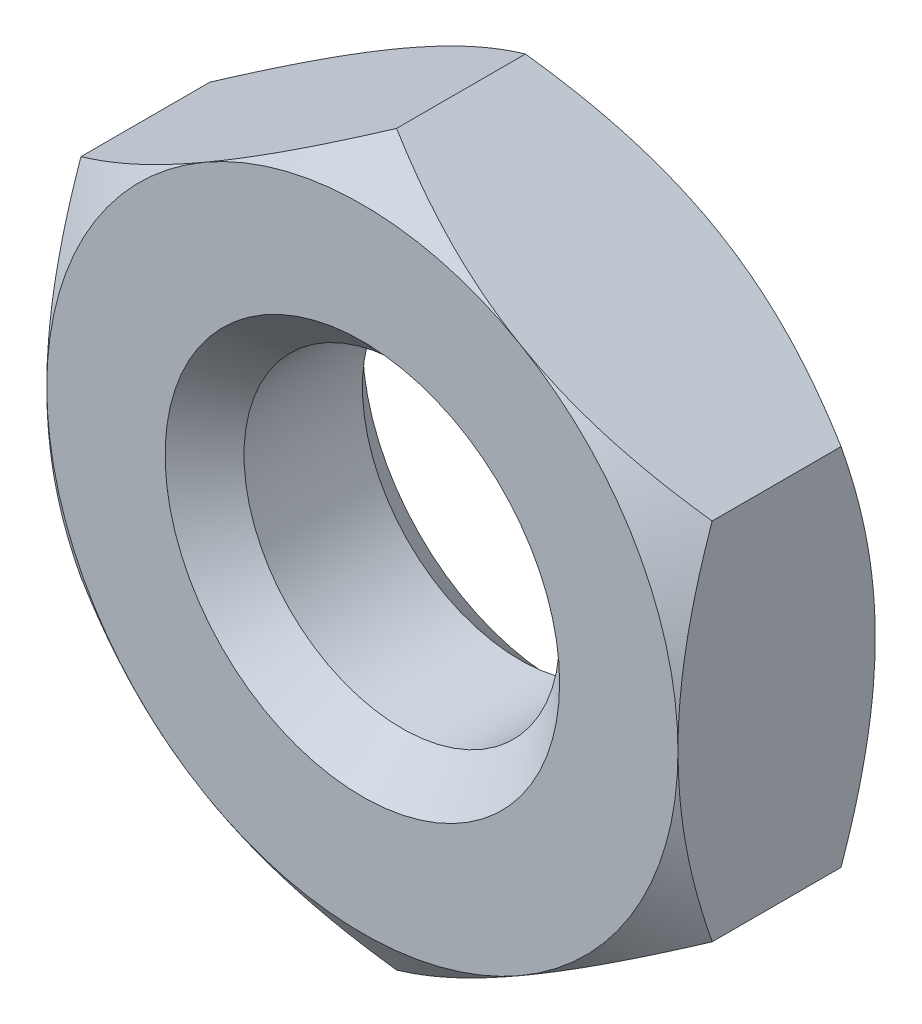
from build123d import *

# Parameters (mm, degrees)
SKETCH1_R           = 4
BOSS_EXTRUDE1_DEPTH = 2.5
SKETCH2_OUTSIDE_W   = 40.128
SKETCH2_OUTSIDE_H   = 42.604
SKETCH2_OUTSIDE_R   = 8
CUT_EXTRUDE1_DEPTH  = 6
CUT_EXTRUDE1_TAPER  = 55
CHAMFER1_SIZE       = 1


with BuildPart() as part:
    # Sketch1 → Boss-Extrude1 (new body, symmetric)
    with BuildSketch(Plane.XY):
        Polygon((-8, 4.618802154), (-8, -4.618802154), (0, -9.237604307), (8, -4.618802154), (8, 4.618802154), (0, 9.237604307), align=None)
        Circle(SKETCH1_R, mode=Mode.SUBTRACT)
    extrude(amount=BOSS_EXTRUDE1_DEPTH, both=True)

    # Sketch2 outside → Cut-Extrude1 (cut, through all)
    with BuildSketch(Plane.XY.offset(2.5)):
        Rectangle(SKETCH2_OUTSIDE_W, SKETCH2_OUTSIDE_H)
        Circle(SKETCH2_OUTSIDE_R, mode=Mode.SUBTRACT)
    cut_extrude1 = extrude(amount=-CUT_EXTRUDE1_DEPTH, taper=CUT_EXTRUDE1_TAPER, mode=Mode.SUBTRACT)

    # Mirror1: Cut-Extrude1 across plane
    add(cut_extrude1.mirror(Plane.XY), mode=Mode.SUBTRACT)

    # Chamfer1
    chamfer1_edges = [part.edges().sort_by_distance(p)[0] for p in [
        (-4, 0, -2.5),
        (-4, 0, 2.5),
    ]]
    chamfer(chamfer1_edges, length=CHAMFER1_SIZE)


solid = part.part
